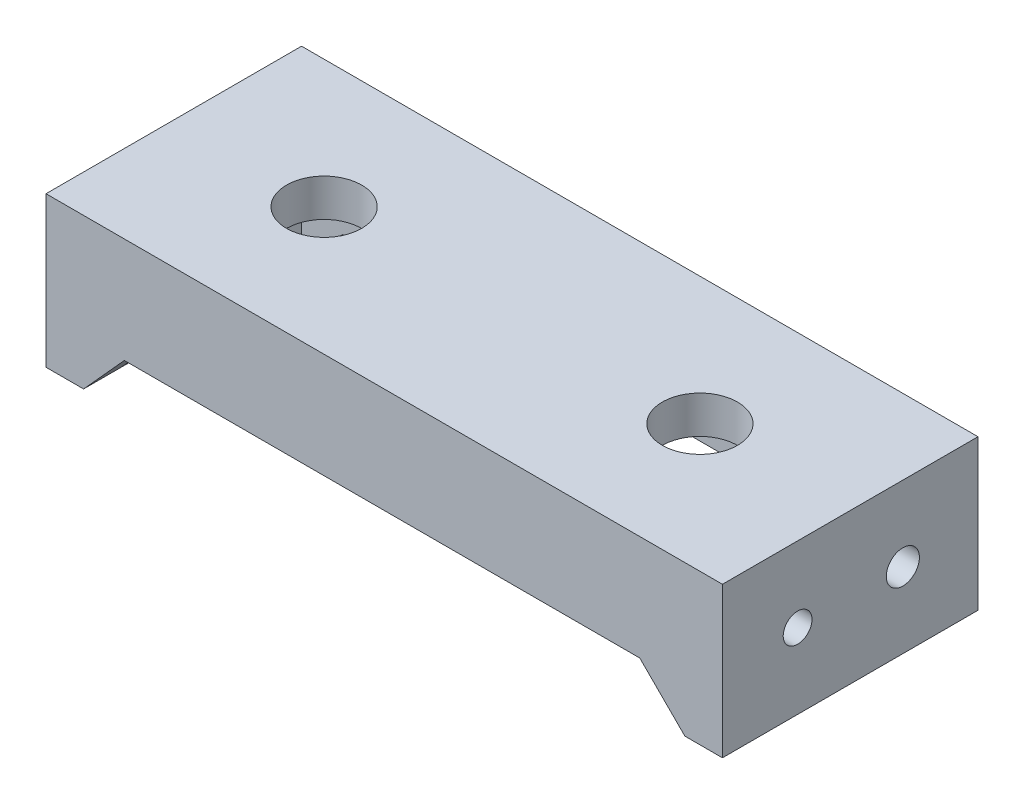
from build123d import *

# Parameters (mm, degrees)
SKETCH1_W           = 45
SKETCH1_H           = 17
BOSS_EXTRUDE1_DEPTH = 2.5
SKETCH2_W           = 45
SKETCH2_H           = 17
SKETCH2_W_2         = 40
SKETCH2_H_2         = 12
BOSS_EXTRUDE2_DEPTH = 4.5
SKETCH3_R           = 0.957368162
SKETCH3_R_2         = 1.102212996
CUT_EXTRUDE1_DEPTH  = 46
SKETCH4_W           = 2.5
SKETCH4_H           = 17
BOSS_EXTRUDE3_DEPTH = 3
BOSS_EXTRUDE4_START = -2.5
BOSS_EXTRUDE4_DEPTH = 2.5
BOSS_EXTRUDE5_DEPTH = 2.5
SKETCH7_R           = 2.5
CUT_EXTRUDE2_DEPTH  = 2.5


with BuildPart() as part:
    # Sketch1 → Boss-Extrude1 (new body)
    with BuildSketch(Plane(origin=(0, 0, 0), x_dir=(1, 0, 0), z_dir=(0, 1, 0))):
        Rectangle(SKETCH1_W, SKETCH1_H)
    extrude(amount=BOSS_EXTRUDE1_DEPTH)

    # Sketch2 → Boss-Extrude2 (add)
    with BuildSketch(Plane.XZ):
        Rectangle(SKETCH2_W, SKETCH2_H)
        Rectangle(SKETCH2_W_2, SKETCH2_H_2, mode=Mode.SUBTRACT)
    extrude(amount=BOSS_EXTRUDE2_DEPTH)

    # Sketch3 → Cut-Extrude1 (cut, through all)
    with BuildSketch(Plane(origin=(22.5, 0, 0), x_dir=(0, 0, -1), z_dir=(1, 0, 0))):
        with Locations((-3.5, -2.5)):
            Circle(SKETCH3_R)
        with Locations((3.5, -2.5)):
            Circle(SKETCH3_R_2)
    extrude(amount=-CUT_EXTRUDE1_DEPTH, mode=Mode.SUBTRACT)

    # Sketch4 → Boss-Extrude3 (add)
    with BuildSketch(Plane.XZ.offset(4.5)):
        with Locations((-21.25, 0)):
            Rectangle(SKETCH4_W, SKETCH4_H)
        with Locations((21.25, 0)):
            Rectangle(SKETCH4_W, SKETCH4_H)
    extrude(amount=BOSS_EXTRUDE3_DEPTH)

    # Sketch5 → Boss-Extrude4 (add)
    with BuildSketch(Plane.XY.offset(8.5).offset(BOSS_EXTRUDE4_START)):
        Polygon((20, -7.5), (20, -4.5), (17, -4.5), align=None)
        Polygon((-20, -7.5), (-20, -4.5), (-17.287649909, -4.5), align=None)
    extrude(amount=BOSS_EXTRUDE4_DEPTH)

    # Sketch6 → Boss-Extrude5 (add)
    with BuildSketch(Plane(origin=(0, 0, -8.5), x_dir=(-1, 0, 0), z_dir=(0, 0, -1))):
        Polygon((20, -4.5), (17.287649909, -4.5), (20, -7.5), align=None)
        Polygon((-17, -4.5), (-20, -4.5), (-20, -7.5), align=None)
    extrude(amount=-BOSS_EXTRUDE5_DEPTH)

    # Sketch7 → Cut-Extrude2 (cut)
    with BuildSketch(Plane(origin=(0, 2.5, 0), x_dir=(1, 0, 0), z_dir=(0, 1, 0))):
        with Locations((-12.5, 0)):
            Circle(SKETCH7_R)
        with Locations((12.5, 0)):
            Circle(SKETCH7_R)
    cut_extrude2 = extrude(amount=-CUT_EXTRUDE2_DEPTH, mode=Mode.SUBTRACT)

    # Mirror1: Cut-Extrude2 across plane
    add(cut_extrude2.mirror(Plane.XY), mode=Mode.SUBTRACT)


solid = part.part
